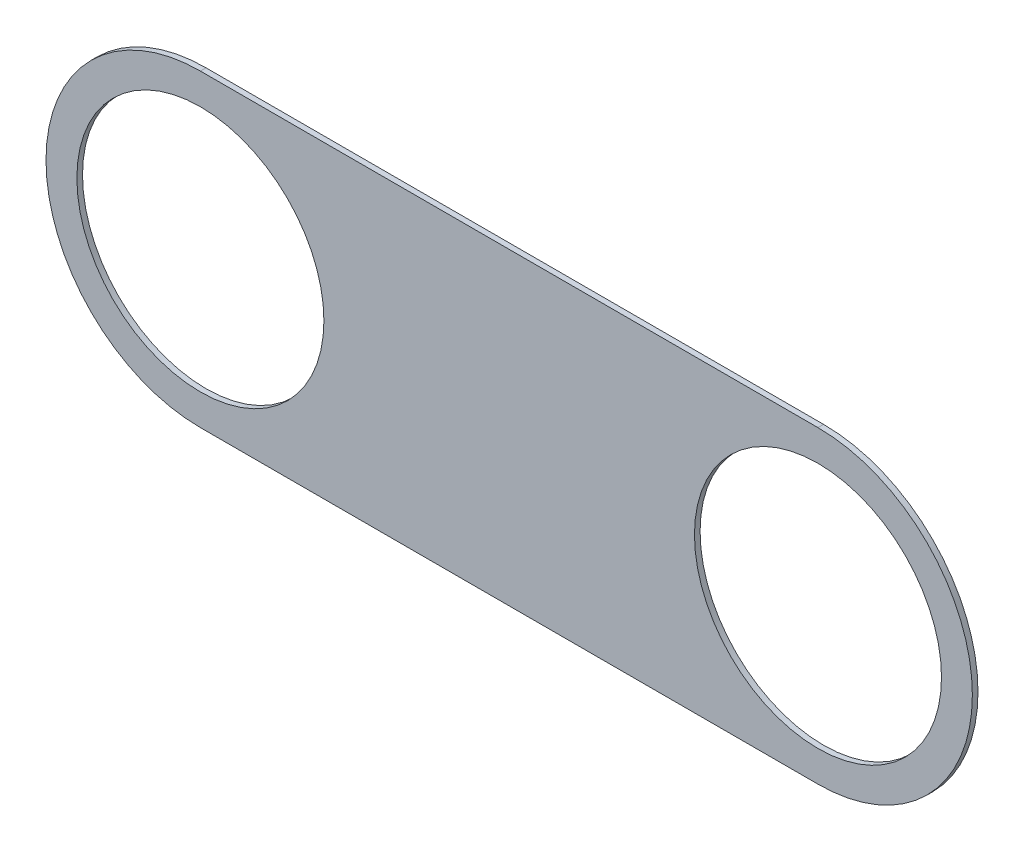
from build123d import *

# Parameters (mm, degrees)
SKETCH2_R           = 25.4
BOSS_EXTRUDE1_DEPTH = 1.15824


with BuildPart() as part:
    # Sketch2 → Boss-Extrude1 (new body)
    with BuildSketch(Plane.XY):
        with BuildLine():
            Line((-63.5, 31.75), (63.5, 31.75))
            ThreePointArc((63.5, 31.75), (95.25, 0), (63.5, -31.75))
            Line((63.5, -31.75), (-63.5, -31.75))
            ThreePointArc((-63.5, -31.75), (-95.25, 0), (-63.5, 31.75))
        make_face()
        with Locations((-63.5, 0)):
            Circle(SKETCH2_R, mode=Mode.SUBTRACT)
        with Locations((63.5, 0)):
            Circle(SKETCH2_R, mode=Mode.SUBTRACT)
    extrude(amount=BOSS_EXTRUDE1_DEPTH)


solid = part.part
